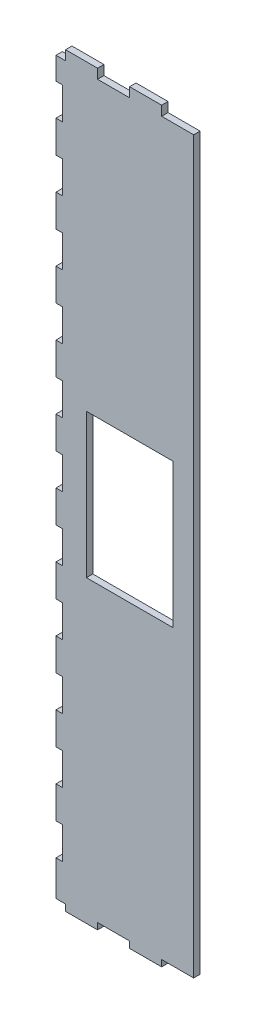
from build123d import *

# Parameters (mm, degrees)
SKETCH1_W               = 40
SKETCH1_H               = 227
BOSS_EXTRUDE1_DEPTH     = 2
SKETCH2_W               = 10
SKETCH2_H               = 2
BOSS_EXTRUDE2_DEPTH     = 3
LPATTERN1_COUNT         = 2
LPATTERN1_PITCH         = 20
SKETCH3_W               = 10
SKETCH3_H               = 2
BOSS_EXTRUDE3_DEPTH     = 3
LPATTERN2_COUNT         = 2
LPATTERN2_PITCH         = 20
SKETCH4_W               = 2
SKETCH4_H               = 10
BOSS_EXTRUDE4_DEPTH     = 3
LPATTERN3_COUNT         = 12
LPATTERN3_PITCH         = 20
ESQUISSE1_W             = 3
ESQUISSE1_H             = 3
ENL_V_MAT_EXTRU_1_DEPTH = 3
ESQUISSE2_W             = 1
ESQUISSE2_H             = 227
ESQUISSE2_W_2           = 43
ESQUISSE2_H_2           = 1
BOSS_EXTRU_1_DEPTH      = 2
ESQUISSE4_W             = 27
ESQUISSE4_H             = 45
ENL_V_MAT_EXTRU_2_DEPTH = 3


with BuildPart() as part:
    # Sketch1 → Boss-Extrude1 (new body)
    with BuildSketch(Plane.XY):
        with Locations((20, 113.5)):
            Rectangle(SKETCH1_W, SKETCH1_H)
    extrude(amount=BOSS_EXTRUDE1_DEPTH)

    # Sketch2 → Boss-Extrude2 (add)
    with BuildSketch(Plane.XZ):
        with Locations((25, 1)):
            Rectangle(SKETCH2_W, SKETCH2_H)
    boss_extrude2 = extrude(amount=BOSS_EXTRUDE2_DEPTH)

    # LPattern1: Boss-Extrude2 ×2
    with Locations(*[(-i * LPATTERN1_PITCH, 0, 0) for i in range(1, LPATTERN1_COUNT)]):
        add(boss_extrude2)

    # Sketch3 → Boss-Extrude3 (add)
    with BuildSketch(Plane(origin=(0, 227, 0), x_dir=(1, 0, 0), z_dir=(0, 1, 0))):
        with Locations((25, -1)):
            Rectangle(SKETCH3_W, SKETCH3_H)
    boss_extrude3 = extrude(amount=BOSS_EXTRUDE3_DEPTH)

    # LPattern2: Boss-Extrude3 ×2
    with Locations(*[(-i * LPATTERN2_PITCH, 0, 0) for i in range(1, LPATTERN2_COUNT)]):
        add(boss_extrude3)

    # Sketch4 → Boss-Extrude4 (add)
    with BuildSketch(Plane.ZY):
        with Locations((1, 5)):
            Rectangle(SKETCH4_W, SKETCH4_H)
    boss_extrude4 = extrude(amount=BOSS_EXTRUDE4_DEPTH)

    # LPattern3: Boss-Extrude4 ×12
    with Locations(*[(0, i * LPATTERN3_PITCH, 0) for i in range(1, LPATTERN3_COUNT)]):
        add(boss_extrude4)

    # Esquisse1 → Enlèv. mat.-Extru.1 (cut, through all)
    with BuildSketch(Plane.XY.offset(2)):
        with Locations((-1.5, 228.5)):
            Rectangle(ESQUISSE1_W, ESQUISSE1_H)
    extrude(amount=-ENL_V_MAT_EXTRU_1_DEPTH, mode=Mode.SUBTRACT)

    # Esquisse2 → Boss.-Extru.1 (add)
    with BuildSketch(Plane.XY.offset(2)):
        with Locations((-0.5, 113.5)):
            Rectangle(ESQUISSE2_W, ESQUISSE2_H)
        with Locations((18.5, -0.5)):
            Rectangle(ESQUISSE2_W_2, ESQUISSE2_H_2)
    extrude(amount=-BOSS_EXTRU_1_DEPTH)

    # Esquisse4 → Enlèv. mat.-Extru.2 (cut)
    with BuildSketch(Plane.XY.offset(2)):
        with Locations((20, 113)):
            Rectangle(ESQUISSE4_W, ESQUISSE4_H)
    extrude(amount=-ENL_V_MAT_EXTRU_2_DEPTH, mode=Mode.SUBTRACT)


solid = part.part
